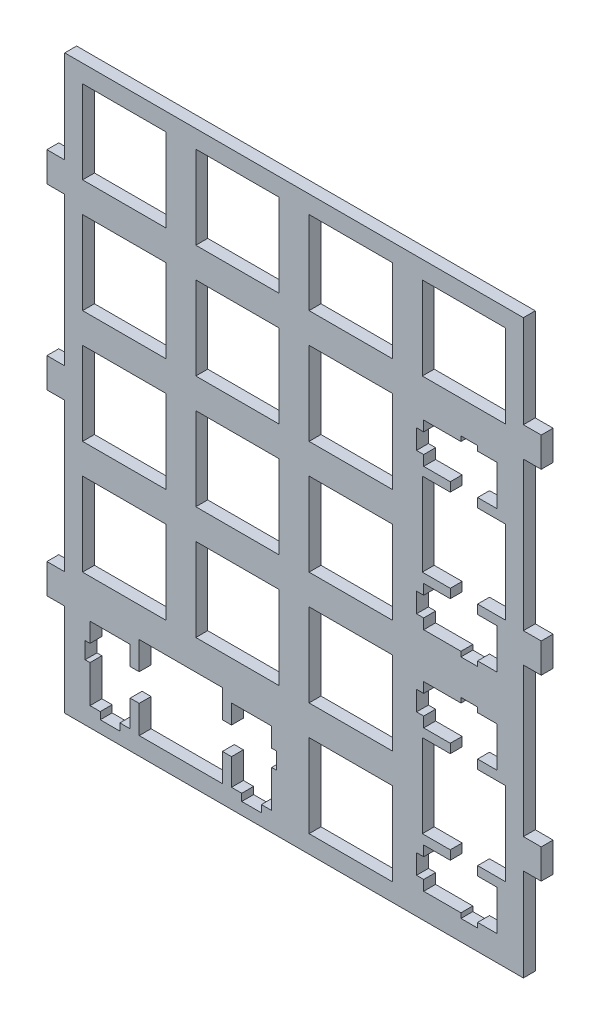
from build123d import *

# Parameters (mm, degrees)
MODEL_W         = 13.9993
MODEL_H         = 13.99946
MODEL_W_2       = 13.99955
MODEL_H_2       = 13.9994
MODEL_H_3       = 13.9993
EXTRUDE_1_DEPTH = 2


with BuildPart() as part:
    # Model → 凸台-拉伸1 (new body)
    with BuildSketch(Plane.XY):
        Polygon((-0.38035, 95.9831), (76.769, 95.9831), (76.769, 80.38337), (79.769, 80.38337), (79.769, 75.38337), (76.769, 75.38337), (76.769, 50.38337), (79.769, 50.38337), (79.769, 45.38337), (76.769, 45.38337), (76.769, 20.38337), (79.769, 20.38337), (79.769, 15.38337), (76.769, 15.38337), (76.769, -0.21636), (-0.38035, -0.21636), (-0.38035, 15.38337), (-3.38035, 15.38337), (-3.38035, 20.38337), (-0.38035, 20.38337), (-0.38035, 45.38337), (-3.38035, 45.38337), (-3.38035, 50.38337), (-0.38035, 50.38337), (-0.38035, 75.38337), (-3.38035, 75.38337), (-3.38035, 80.38337), (-0.38035, 80.38337), align=None)
        Polygon((12.1447, 16.7831), (12.1447, 12.0826), (10.6192, 12.0826), (10.6192, 15.3128), (3.86955, 15.3128), (3.86955, 12.0826), (3.04409, 12.0826), (3.04409, 9.28384), (3.86955, 9.28384), (3.86955, 3.01377), (5.59484, 3.01377), (5.59484, 1.8135), (8.89385, 1.8135), (8.89385, 3.01377), (10.6192, 3.01377), (10.6192, 7.48273), (12.1447, 7.48273), (12.1447, 2.78364), (26.1441, 2.78364), (26.1441, 7.48273), (27.6696, 7.48273), (27.6696, 3.01377), (29.3949, 3.01377), (29.3949, 1.8135), (32.694, 1.8135), (32.694, 3.01377), (34.4193, 3.01377), (34.4193, 9.28384), (35.2447, 9.28384), (35.2447, 12.0826), (34.4193, 12.0826), (34.4193, 15.3128), (27.6696, 15.3128), (27.6696, 12.0826), (26.1441, 12.0826), (26.1441, 16.7831), align=None, mode=Mode.SUBTRACT)
        with Locations((47.71935, 9.78337)):
            Rectangle(MODEL_W, MODEL_H, mode=Mode.SUBTRACT)
        Polygon((66.27, 35.4087), (66.27, 34.5833), (59.9997, 34.5833), (59.9997, 32.8579), (58.7996, 32.8579), (58.7996, 29.5589), (59.9997, 29.5589), (59.9997, 27.8336), (64.4701, 27.8336), (64.4701, 26.3081), (59.7697, 26.3081), (59.7697, 12.3086), (64.4701, 12.3086), (64.4701, 10.7831), (59.9997, 10.7831), (59.9997, 9.05785), (58.7996, 9.05785), (58.7996, 5.75881), (59.9997, 5.75881), (59.9997, 4.03352), (66.27, 4.03352), (66.27, 3.20807), (69.07, 3.20807), (69.07, 4.03352), (72.3, 4.03352), (72.3, 10.7831), (69.07, 10.7831), (69.07, 12.3086), (73.769, 12.3086), (73.769, 26.3081), (69.07, 26.3081), (69.07, 27.8336), (72.3, 27.8336), (72.3, 34.5833), (69.07, 34.5833), (69.07, 35.4087), align=None, mode=Mode.SUBTRACT)
        with Locations((9.619425, 28.8333)):
            Rectangle(MODEL_W_2, MODEL_H_2, mode=Mode.SUBTRACT)
        with Locations((28.66935, 28.8333)):
            Rectangle(MODEL_W, MODEL_H_2, mode=Mode.SUBTRACT)
        with Locations((47.71935, 28.8333)):
            Rectangle(MODEL_W, MODEL_H_2, mode=Mode.SUBTRACT)
        with Locations((9.619425, 47.88345)):
            Rectangle(MODEL_W_2, MODEL_H_3, mode=Mode.SUBTRACT)
        with Locations((28.66935, 47.88345)):
            Rectangle(MODEL_W, MODEL_H_3, mode=Mode.SUBTRACT)
        with Locations((47.71935, 47.88345)):
            Rectangle(MODEL_W, MODEL_H_3, mode=Mode.SUBTRACT)
        Polygon((66.27, 73.5087), (66.27, 72.6832), (59.9997, 72.6832), (59.9997, 70.9581), (58.7996, 70.9581), (58.7996, 67.6589), (59.9997, 67.6589), (59.9997, 65.9335), (64.4701, 65.9335), (64.4701, 64.4081), (59.7697, 64.4081), (59.7697, 50.4088), (64.4701, 50.4088), (64.4701, 48.883), (59.9997, 48.883), (59.9997, 47.1579), (58.7996, 47.1579), (58.7996, 43.8587), (59.9997, 43.8587), (59.9997, 42.1337), (66.27, 42.1337), (66.27, 41.3082), (69.07, 41.3082), (69.07, 42.1337), (72.3, 42.1337), (72.3, 48.883), (69.07, 48.883), (69.07, 50.4088), (73.769, 50.4088), (73.769, 64.4081), (69.07, 64.4081), (69.07, 65.9335), (72.3, 65.9335), (72.3, 72.6832), (69.07, 72.6832), (69.07, 73.5087), align=None, mode=Mode.SUBTRACT)
        with Locations((9.619425, 66.93345)):
            Rectangle(MODEL_W_2, MODEL_H_3, mode=Mode.SUBTRACT)
        with Locations((28.66935, 66.93345)):
            Rectangle(MODEL_W, MODEL_H_3, mode=Mode.SUBTRACT)
        with Locations((47.71935, 66.93345)):
            Rectangle(MODEL_W, MODEL_H_3, mode=Mode.SUBTRACT)
        with Locations((9.619425, 85.98345)):
            Rectangle(MODEL_W_2, MODEL_H_3, mode=Mode.SUBTRACT)
        with Locations((28.66935, 85.98345)):
            Rectangle(MODEL_W, MODEL_H_3, mode=Mode.SUBTRACT)
        with Locations((47.71935, 85.98345)):
            Rectangle(MODEL_W, MODEL_H_3, mode=Mode.SUBTRACT)
        with Locations((66.76935, 85.98345)):
            Rectangle(MODEL_W, MODEL_H_3, mode=Mode.SUBTRACT)
    extrude(amount=EXTRUDE_1_DEPTH)


solid = part.part
